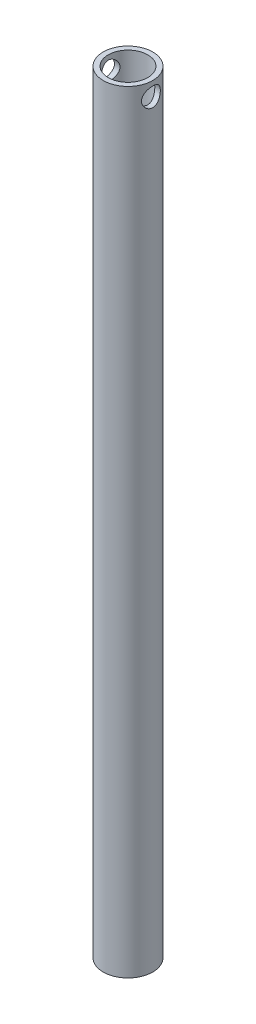
from build123d import *

# Parameters (mm, degrees)
SKETCH1_R               = 16.7005
SKETCH1_R_2             = 13.335
BOSS_EXTRUDE1_DEPTH     = 520.7
SKETCH2_R               = 6.35
CUT_EXTRUDE1_DEPTH      = 17.7005
CUT_EXTRUDE1_DEPTH_BACK = 17.7005


with BuildPart() as part:
    # Sketch1 → Boss-Extrude1 (new body)
    with BuildSketch(Plane(origin=(0, 0, 0), x_dir=(1, 0, 0), z_dir=(0, 1, 0))):
        Circle(SKETCH1_R)
        Circle(SKETCH1_R_2, mode=Mode.SUBTRACT)
    extrude(amount=BOSS_EXTRUDE1_DEPTH)

    # Sketch2 → Cut-Extrude1 (cut, two sides)
    with BuildSketch(Plane(origin=(0, 0, 0), x_dir=(0, 0, -1), z_dir=(1, 0, 0))) as cut_extrude1_sk:
        with Locations((0, 511.175)):
            Circle(SKETCH2_R)
    extrude(amount=CUT_EXTRUDE1_DEPTH, mode=Mode.SUBTRACT)
    extrude(cut_extrude1_sk.sketch, amount=-CUT_EXTRUDE1_DEPTH_BACK, mode=Mode.SUBTRACT)


solid = part.part
